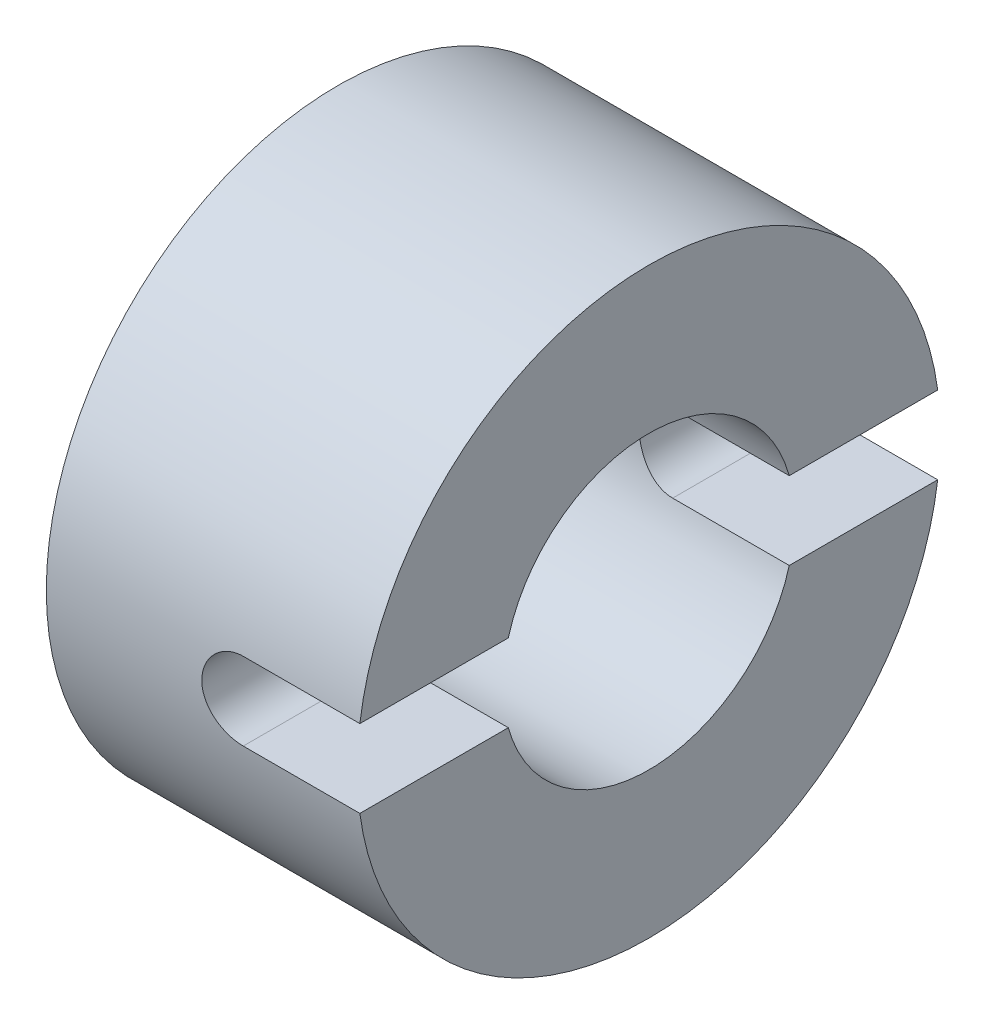
from build123d import *

# Parameters (mm, degrees)
ESQUISSE1_W             = 8
ESQUISSE1_H             = 3.75
ENL_V_MAT_EXTRU_2_DEPTH = 25


with BuildPart() as part:
    # Esquisse1 → R_volution1 (revolve)
    with BuildSketch(Plane.XY, mode=Mode.PRIVATE) as r_volution1_sk:
        with Locations((-8.673814, 5.625)):
            Rectangle(ESQUISSE1_W, ESQUISSE1_H)
    revolve(r_volution1_sk.sketch.rotate(Axis((-26.499793814, 0, 0), (1, 0, 0)), 90), axis=Axis((-26.499793814, 0, 0), (1, 0, 0)))  # turned: the seam where the file's is

    # Esquisse2 → Enl_v. mat.-Extru.2 (cut, symmetric)
    with BuildSketch(Plane.XY):
        with BuildLine():
            Line((-8.673814, 0), (-4.141062675, 0))
            Line((-4.141062675, 0), (-4.145756794, 1))
            Line((-4.145756794, 1), (-7.673814, 1))
            ThreePointArc((-7.673814, 1), (-8.380920781, 0.707106781), (-8.673814, 0))
        make_face()
        with BuildLine():
            Line((-7.673814, -1), (-4.136368556, -1))
            Line((-4.136368556, -1), (-4.141062675, 0))
            Line((-4.141062675, 0), (-8.673814, 0))
            ThreePointArc((-8.673814, 0), (-8.380920781, -0.707106781), (-7.673814, -1))
        make_face()
    extrude(amount=ENL_V_MAT_EXTRU_2_DEPTH, both=True, mode=Mode.SUBTRACT)


solid = part.part
